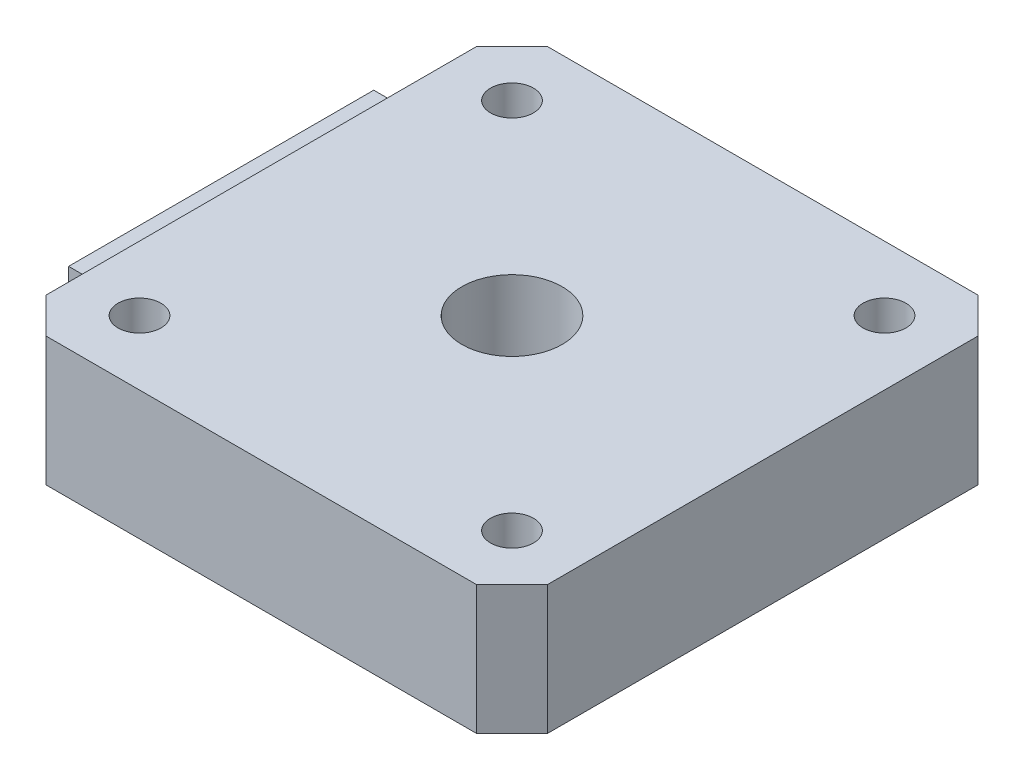
from build123d import *

# Parameters (mm, degrees)
SALIENTE_EXTRUIR1_DEPTH = 9
CROQUIS2_R              = 3.5
CORTAR_EXTRUIR1_DEPTH   = 10
CROQUIS3_R              = 1.5
CORTAR_EXTRUIR2_DEPTH   = 10
SKETCH1_W               = 21.3
SKETCH1_H               = 7.15
BOSS_EXTRUDE1_DEPTH     = 2.8
SKETCH2_W               = 20
SKETCH2_H               = 6
CUT_EXTRUDE1_DEPTH      = 2.8


with BuildPart() as part:
    # Croquis1 → Saliente-Extruir1 (new body)
    with BuildSketch(Plane(origin=(0, 0, 0), x_dir=(1, 0, 0), z_dir=(0, 1, 0))):
        Polygon((0, 2.473088065), (2.473088065, 0), (32.526911935, 0), (35, 2.473088065), (35, 32.526911935), (32.526911935, 35), (2.473088065, 35), (0, 32.526911935), align=None)
    extrude(amount=SALIENTE_EXTRUIR1_DEPTH)

    # Croquis2 → Cortar-Extruir1 (cut, through all)
    with BuildSketch(Plane(origin=(0, 9, 0), x_dir=(1, 0, 0), z_dir=(0, 1, 0))):
        with Locations((17.5, 17.5)):
            Circle(CROQUIS2_R)
    extrude(amount=-CORTAR_EXTRUIR1_DEPTH, mode=Mode.SUBTRACT)

    # Croquis3 → Cortar-Extruir2 (cut, through all)
    with BuildSketch(Plane(origin=(0, 9, 0), x_dir=(1, 0, 0), z_dir=(0, 1, 0))):
        with Locations((4.5, 30.5)):
            Circle(CROQUIS3_R)
        with Locations((30.5, 30.5)):
            Circle(CROQUIS3_R)
        with Locations((30.5, 4.5)):
            Circle(CROQUIS3_R)
        with Locations((4.5, 4.5)):
            Circle(CROQUIS3_R)
    extrude(amount=-CORTAR_EXTRUIR2_DEPTH, mode=Mode.SUBTRACT)

    # Sketch1 → Boss-Extrude1 (add)
    with BuildSketch(Plane.ZY):
        with Locations((-17.5, 3.575)):
            Rectangle(SKETCH1_W, SKETCH1_H)
    extrude(amount=BOSS_EXTRUDE1_DEPTH)

    # Sketch2 → Cut-Extrude1 (cut)
    with BuildSketch(Plane.ZY.offset(2.8)):
        with Locations((-17.5, 3.575)):
            Rectangle(SKETCH2_W, SKETCH2_H)
    extrude(amount=-CUT_EXTRUDE1_DEPTH, mode=Mode.SUBTRACT)


solid = part.part
